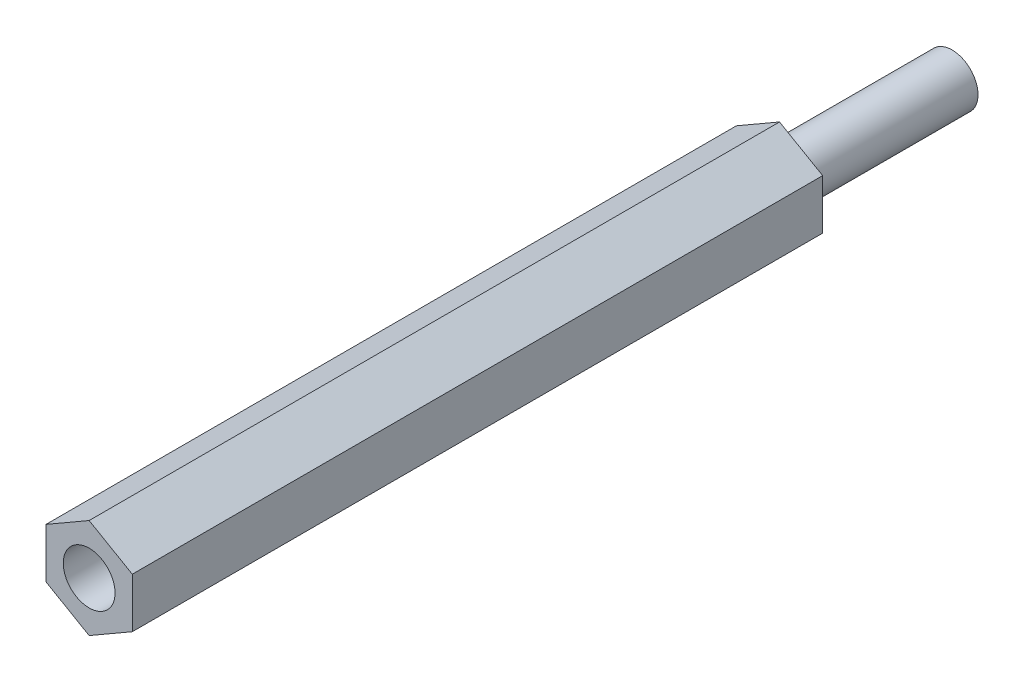
from build123d import *

# Parameters (mm, degrees)
ESQUISSE1_R             = 1.5
BOSS_EXTRU_2_DEPTH      = 40
ESQUISSE3_R             = 1.5
BOSS_EXTRU_3_DEPTH      = 10
BOSS_EXTRU_3_DEPTH_BACK = 30


with BuildPart() as part:
    # Esquisse1 → Boss.-Extru.2 (new body)
    with BuildSketch(Plane.XY):
        Polygon((0, -2.886751346), (2.5, -1.443375673), (2.5, 1.443375673), (0, 2.886751346), (-2.5, 1.443375673), (-2.5, -1.443375673), align=None)
        Circle(ESQUISSE1_R, mode=Mode.SUBTRACT)
    extrude(amount=BOSS_EXTRU_2_DEPTH)

    # Esquisse3 → Boss.-Extru.3 (add, two sides)
    with BuildSketch(Plane(origin=(0, 0, 0), x_dir=(-1, 0, 0), z_dir=(0, 0, -1))) as boss_extru_3_sk:
        Circle(ESQUISSE3_R)
    extrude(amount=BOSS_EXTRU_3_DEPTH)
    extrude(boss_extru_3_sk.sketch, amount=-BOSS_EXTRU_3_DEPTH_BACK)


solid = part.part
